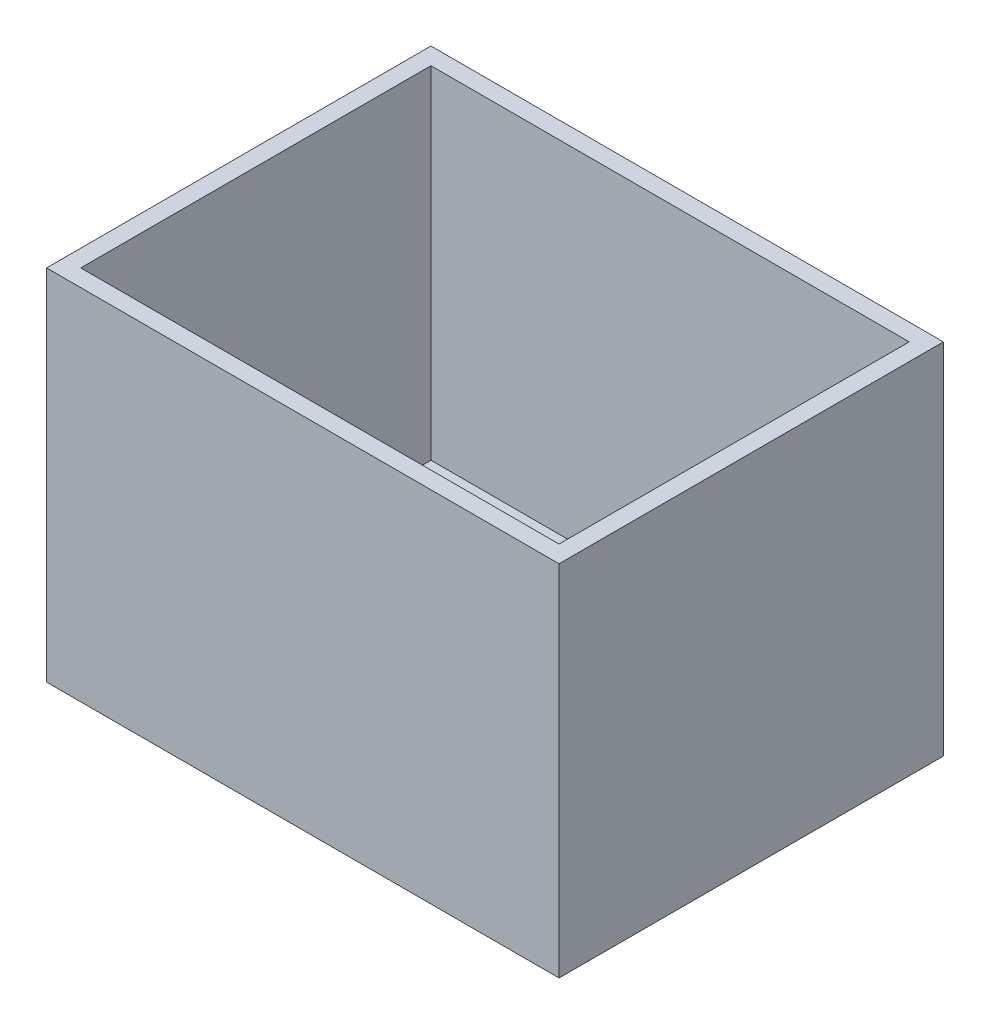
from build123d import *

# Parameters (mm, degrees)
SKETCH1_W           = 600
SKETCH1_H           = 450
SKETCH1_W_2         = 560
SKETCH1_H_2         = 410
BOSS_EXTRUDE1_DEPTH = 400
SKETCH2_W           = 600
SKETCH2_H           = 450
BOSS_EXTRUDE2_DEPTH = 20


with BuildPart() as part:
    # Sketch1 → Boss-Extrude1 (new body)
    with BuildSketch(Plane(origin=(0, 0, 0), x_dir=(1, 0, 0), z_dir=(0, 1, 0))):
        Rectangle(SKETCH1_W, SKETCH1_H)
        Rectangle(SKETCH1_W_2, SKETCH1_H_2, mode=Mode.SUBTRACT)
    extrude(amount=BOSS_EXTRUDE1_DEPTH)

    # Sketch2 → Boss-Extrude2 (add)
    with BuildSketch(Plane.XZ):
        Rectangle(SKETCH2_W, SKETCH2_H)
    extrude(amount=BOSS_EXTRUDE2_DEPTH)


solid = part.part
